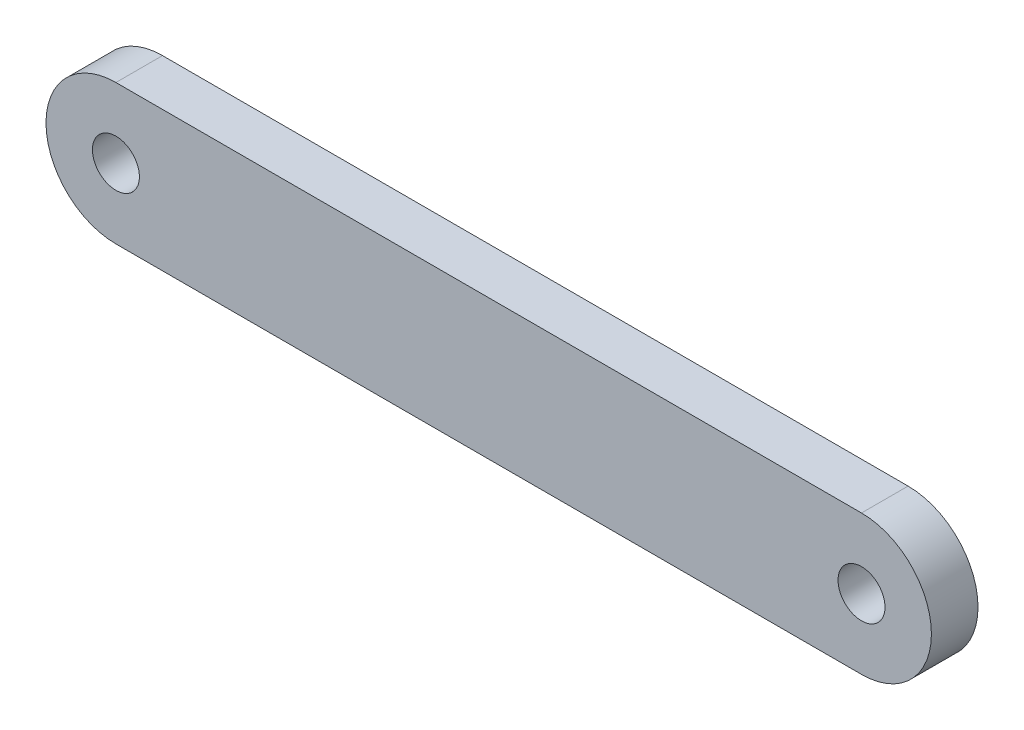
from build123d import *

# Parameters (mm, degrees)
BOSS_EXTRUDE1_DEPTH       = 1.5875
F_1_8_0_126_DOWEL_HOLE1_D = 3.2004


with BuildPart() as part:
    # Sketch1 → Boss-Extrude1 (new body, symmetric)
    with BuildSketch(Plane.XY):
        with BuildLine():
            Line((-25.4, 4.7625), (25.4, 4.7625))
            ThreePointArc((25.4, 4.7625), (30.1625, 0), (25.4, -4.7625))
            Line((25.4, -4.7625), (-25.4, -4.7625))
            ThreePointArc((-25.4, -4.7625), (-30.1625, 0), (-25.4, 4.7625))
        make_face()
    extrude(amount=BOSS_EXTRUDE1_DEPTH, both=True)

    # 1/8 (0.126) Dowel Hole1 (through all)
    with Locations(Plane.XY.offset(1.5875)):
        with Locations((-25.4, 0), (25.4, 0)):
            Hole(F_1_8_0_126_DOWEL_HOLE1_D / 2)


solid = part.part
